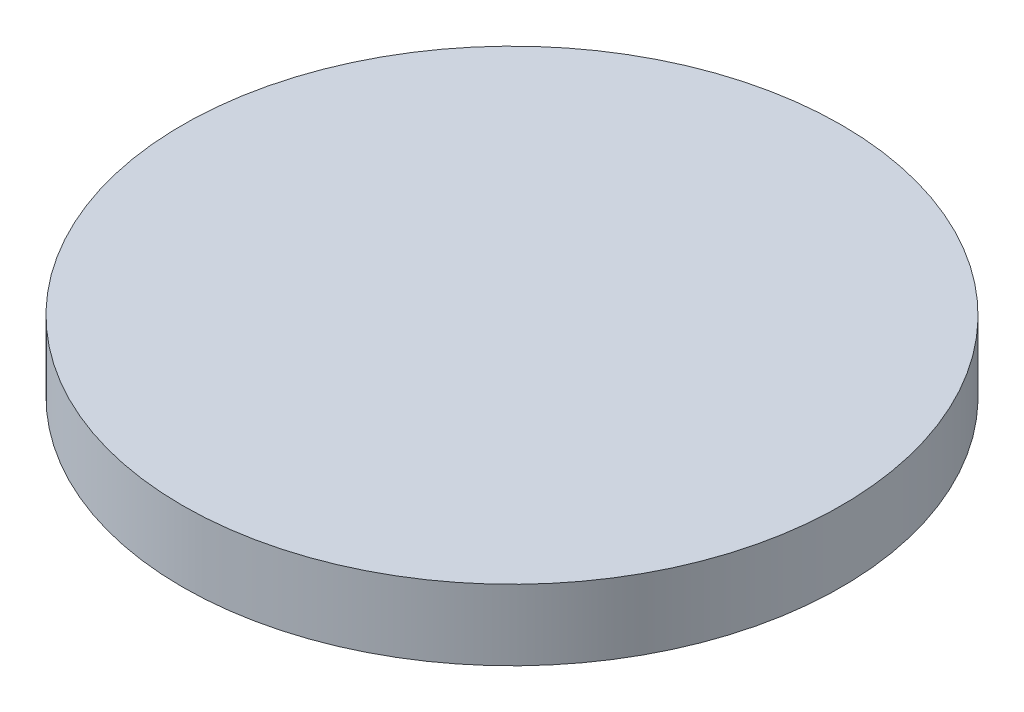
from build123d import *

# Parameters (mm, degrees)
SKETCH1_R           = 3.556
BOSS_EXTRUDE1_DEPTH = 0.762


with BuildPart() as part:
    # Sketch1 → Boss-Extrude1 (new body)
    with BuildSketch(Plane(origin=(0, 0, 0), x_dir=(1, 0, 0), z_dir=(0, 1, 0))):
        Circle(SKETCH1_R)
    extrude(amount=BOSS_EXTRUDE1_DEPTH)


solid = part.part
